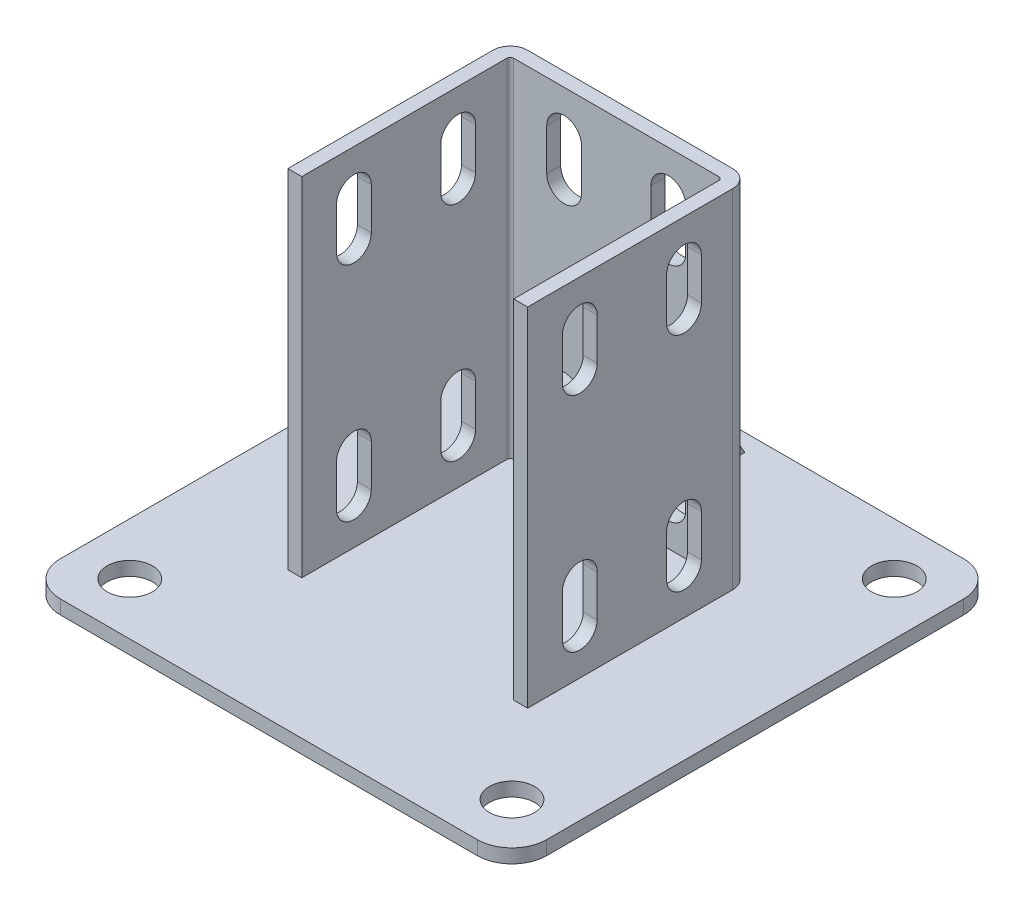
from build123d import *

# Parameters (mm, degrees)
SKETCH_2_W          = 140
SKETCH_2_H          = 140
EXTRUDE_1_DEPTH     = 4
EXTRUDE_1_2_DEPTH   = 100
EXTRUDE_2_DEPTH     = 2
CUT_EXTRUDE_1_DEPTH = 105.5
SKETCH_6_R          = 6.5
CUT_EXTRUDE_2_DEPTH = 5
FILLET_1_R          = 10
CUT_EXTRUDE_3_REACH = 106


with BuildPart() as part:
    # Эскиз2 → Extrude 1 (new body)
    with BuildSketch(Plane(origin=(0, 0, 0), x_dir=(1, 0, 0), z_dir=(0, 1, 0))):
        Rectangle(SKETCH_2_W, SKETCH_2_H)
    extrude(amount=EXTRUDE_1_DEPTH)

    # Эскиз3 → Extrude 1 2 (add)
    with BuildSketch(Plane(origin=(0, 4, 0), x_dir=(1, 0, 0), z_dir=(0, 1, 0))):
        with BuildLine():
            Line((-30.5, -30), (-30.5, 29))
            ThreePointArc((-30.5, 29), (-30.207106781, 29.707106781), (-29.5, 30))
            Line((-29.5, 30), (29.5, 30))
            ThreePointArc((29.5, 30), (30.207106781, 29.707106781), (30.5, 29))
            Line((30.5, 29), (30.5, -30))
            Line((30.5, -30), (34.5, -30))
            Line((34.5, -30), (34.5, 29))
            ThreePointArc((34.5, 29), (33.035533906, 32.535533906), (29.5, 34))
            Line((29.5, 34), (-29.5, 34))
            ThreePointArc((-29.5, 34), (-33.035533906, 32.535533906), (-34.5, 29))
            Line((-34.5, 29), (-34.5, -30))
            Line((-34.5, -30), (-30.5, -30))
        make_face()
    extrude(amount=EXTRUDE_1_2_DEPTH)

    # Эскиз4 → Бобышка-Вытянуть2 (add, symmetric)
    with BuildSketch(Plane(origin=(0, 0, 0), x_dir=(0, 0, -1), z_dir=(1, 0, 0))):
        Polygon((34, 57.693575035), (65, 4), (34, 4), align=None)
    extrude(amount=EXTRUDE_2_DEPTH, both=True)

    # Эскиз5 → Вырез-Вытянуть1 (cut, through all)
    with BuildSketch(Plane(origin=(34.5, 0, 0), x_dir=(0, 0, -1), z_dir=(1, 0, 0))):
        with BuildLine():
            Line((-10, 92), (-10, 80))
            ThreePointArc((-10, 80), (-15, 75), (-20, 80))
            Line((-20, 80), (-20, 92))
            ThreePointArc((-20, 92), (-15, 97), (-10, 92))
        make_face()
        with BuildLine():
            Line((-10, 28), (-10, 16))
            ThreePointArc((-10, 16), (-15, 11), (-20, 16))
            Line((-20, 16), (-20, 28))
            ThreePointArc((-20, 28), (-15, 33), (-10, 28))
        make_face()
        with BuildLine():
            Line((10, 92), (10, 80))
            ThreePointArc((10, 80), (15, 75), (20, 80))
            Line((20, 80), (20, 92))
            ThreePointArc((20, 92), (15, 97), (10, 92))
        make_face()
        with BuildLine():
            Line((10, 28), (10, 16))
            ThreePointArc((10, 16), (15, 11), (20, 16))
            Line((20, 16), (20, 28))
            ThreePointArc((20, 28), (15, 33), (10, 28))
        make_face()
    extrude(amount=-CUT_EXTRUDE_1_DEPTH, mode=Mode.SUBTRACT)

    # Эскиз6 → Вырез-Вытянуть2 (cut, through all)
    with BuildSketch(Plane(origin=(0, 4, 0), x_dir=(1, 0, 0), z_dir=(0, 1, 0))):
        with Locations(Location((-55, 55, 0), (0, 0, 270))):  # turned: the seam where the file's is
            Circle(SKETCH_6_R)
        with Locations(Location((-55, -55, 0), (0, 0, 270))):  # turned: the seam where the file's is
            Circle(SKETCH_6_R)
        with Locations(Location((55, 55, 0), (0, 0, 270))):  # turned: the seam where the file's is
            Circle(SKETCH_6_R)
        with Locations(Location((55, -55, 0), (0, 0, 270))):  # turned: the seam where the file's is
            Circle(SKETCH_6_R)
    extrude(amount=-CUT_EXTRUDE_2_DEPTH, mode=Mode.SUBTRACT)

    # Скругление1
    fillet_1_edges = [part.edges().sort_by_distance(p)[0] for p in [
        (70, 2, 70),
        (-70, 2, 70),
        (-70, 2, -70),
        (70, 2, -70),
    ]]
    fillet(fillet_1_edges, radius=FILLET_1_R)

    # Эскиз8 → Вырез-Вытянуть3 (cut, up to next)
    with BuildSketch(Plane(origin=(0, 0, -34), x_dir=(-1, 0, 0), z_dir=(0, 0, -1)), mode=Mode.PRIVATE) as cut_extrude_3_sk1:
        with BuildLine():
            Line((-10, 92), (-10, 80))
            ThreePointArc((-10, 80), (-15, 75), (-20, 80))
            Line((-20, 80), (-20, 92))
            ThreePointArc((-20, 92), (-15, 97), (-10, 92))
        make_face()
    cut_extrude_3_tool1 = extrude(cut_extrude_3_sk1.sketch, amount=-CUT_EXTRUDE_3_REACH, mode=Mode.PRIVATE) & part.part
    add(cut_extrude_3_tool1.solids().sort_by_distance((15, 86, -34))[0], mode=Mode.SUBTRACT)
    # Эскиз8 → Вырез-Вытянуть3 (cut, up to next)
    with BuildSketch(Plane(origin=(0, 0, -34), x_dir=(-1, 0, 0), z_dir=(0, 0, -1)), mode=Mode.PRIVATE) as cut_extrude_3_sk2:
        with BuildLine():
            Line((-10, 28), (-10, 16))
            ThreePointArc((-10, 16), (-15, 11), (-20, 16))
            Line((-20, 16), (-20, 28))
            ThreePointArc((-20, 28), (-15, 33), (-10, 28))
        make_face()
    cut_extrude_3_tool2 = extrude(cut_extrude_3_sk2.sketch, amount=-CUT_EXTRUDE_3_REACH, mode=Mode.PRIVATE) & part.part
    add(cut_extrude_3_tool2.solids().sort_by_distance((15, 22, -34))[0], mode=Mode.SUBTRACT)
    # Эскиз8 → Вырез-Вытянуть3 (cut, up to next)
    with BuildSketch(Plane(origin=(0, 0, -34), x_dir=(-1, 0, 0), z_dir=(0, 0, -1)), mode=Mode.PRIVATE) as cut_extrude_3_sk3:
        with BuildLine():
            Line((10, 92), (10, 80))
            ThreePointArc((10, 80), (15, 75), (20, 80))
            Line((20, 80), (20, 92))
            ThreePointArc((20, 92), (15, 97), (10, 92))
        make_face()
    cut_extrude_3_tool3 = extrude(cut_extrude_3_sk3.sketch, amount=-CUT_EXTRUDE_3_REACH, mode=Mode.PRIVATE) & part.part
    add(cut_extrude_3_tool3.solids().sort_by_distance((-15, 86, -34))[0], mode=Mode.SUBTRACT)
    # Эскиз8 → Вырез-Вытянуть3 (cut, up to next)
    with BuildSketch(Plane(origin=(0, 0, -34), x_dir=(-1, 0, 0), z_dir=(0, 0, -1)), mode=Mode.PRIVATE) as cut_extrude_3_sk4:
        with BuildLine():
            Line((10, 28), (10, 16))
            ThreePointArc((10, 16), (15, 11), (20, 16))
            Line((20, 16), (20, 28))
            ThreePointArc((20, 28), (15, 33), (10, 28))
        make_face()
    cut_extrude_3_tool4 = extrude(cut_extrude_3_sk4.sketch, amount=-CUT_EXTRUDE_3_REACH, mode=Mode.PRIVATE) & part.part
    add(cut_extrude_3_tool4.solids().sort_by_distance((-15, 22, -34))[0], mode=Mode.SUBTRACT)


solid = part.part
